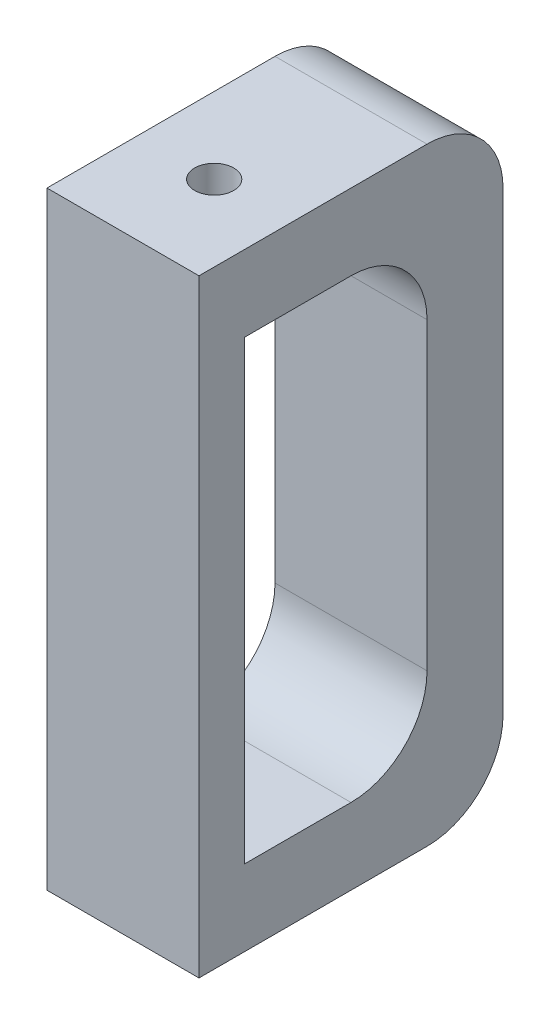
from build123d import *

# Parameters (mm, degrees)
BOSS_EXTRUDE1_DEPTH     = 101.6
SKETCH3_W               = 25.4
SKETCH3_H               = 101.6
BOSS_EXTRUDE2_DEPTH     = 50.8
CUT_EXTRUDE2_DEPTH      = 25.4
SKETCH6_R               = 3.2639
CUT_EXTRUDE3_DEPTH      = 101.6
SKETCH7_W               = 15.875
SKETCH7_H               = 7.928770879
CUT_EXTRUDE4_DEPTH      = 1
CUT_EXTRUDE4_DEPTH_BACK = 102.6


with BuildPart() as part:
    # Sketch2 → Boss-Extrude1 (new body)
    with BuildSketch(Plane(origin=(0, 0, 0), x_dir=(1, 0, 0), z_dir=(0, 1, 0))):
        Polygon((0, 2.159), (0, 0), (-3.937, 0), (0, -5.769770879), (6.35, -5.769770879), (10.287, 0), (6.35, 0), (6.35, 2.159), align=None)
    extrude(amount=-BOSS_EXTRUDE1_DEPTH)

    # Sketch3 → Boss-Extrude2 (add)
    with BuildSketch(Plane(origin=(0, 0, -2.159), x_dir=(-1, 0, 0), z_dir=(0, 0, -1))):
        with Locations((-3.175, -50.8)):
            Rectangle(SKETCH3_W, SKETCH3_H)
    extrude(amount=BOSS_EXTRUDE2_DEPTH)

    # Sketch5 → Cut-Extrude2 (cut)
    with BuildSketch(Plane(origin=(15.875, 0, 0), x_dir=(0, 0, -1), z_dir=(1, 0, 0))):
        with BuildLine():
            ThreePointArc((52.959, -88.9), (49.239256121, -97.880256121), (40.259, -101.6))
            Line((40.259, -101.6), (52.959, -101.6))
            Line((52.959, -101.6), (52.959, -88.9))
        make_face()
        with BuildLine():
            Line((52.959, 0), (40.259, 0))
            ThreePointArc((40.259, 0), (49.239256121, -3.719743879), (52.959, -12.7))
            Line((52.959, -12.7), (52.959, 0))
        make_face()
        with BuildLine():
            Line((40.259, -76.2), (40.259, -25.4))
            ThreePointArc((40.259, -25.4), (36.539256121, -16.419743879), (27.559, -12.7))
            Line((27.559, -12.7), (9.779, -12.7))
            Line((9.779, -12.7), (9.779, -88.9))
            Line((9.779, -88.9), (27.559, -88.9))
            ThreePointArc((27.559, -88.9), (36.539256121, -85.180256121), (40.259, -76.2))
        make_face()
    extrude(amount=-CUT_EXTRUDE2_DEPTH, mode=Mode.SUBTRACT)

    # Sketch6 → Cut-Extrude3 (cut)
    with BuildSketch(Plane(origin=(0, 0, 0), x_dir=(1, 0, 0), z_dir=(0, 1, 0))):
        with Locations((3.175, 17.399)):
            Circle(SKETCH6_R)
    extrude(amount=-CUT_EXTRUDE3_DEPTH, mode=Mode.SUBTRACT)

    # Sketch7 → Cut-Extrude4 (cut, two sides)
    with BuildSketch(Plane(origin=(0, 0, 0), x_dir=(1, 0, 0), z_dir=(0, 1, 0))) as cut_extrude4_sk:
        with Locations((3.175, -1.805385439)):
            Rectangle(SKETCH7_W, SKETCH7_H)
    extrude(amount=CUT_EXTRUDE4_DEPTH, mode=Mode.SUBTRACT)
    extrude(cut_extrude4_sk.sketch, amount=-CUT_EXTRUDE4_DEPTH_BACK, mode=Mode.SUBTRACT)


solid = part.part
